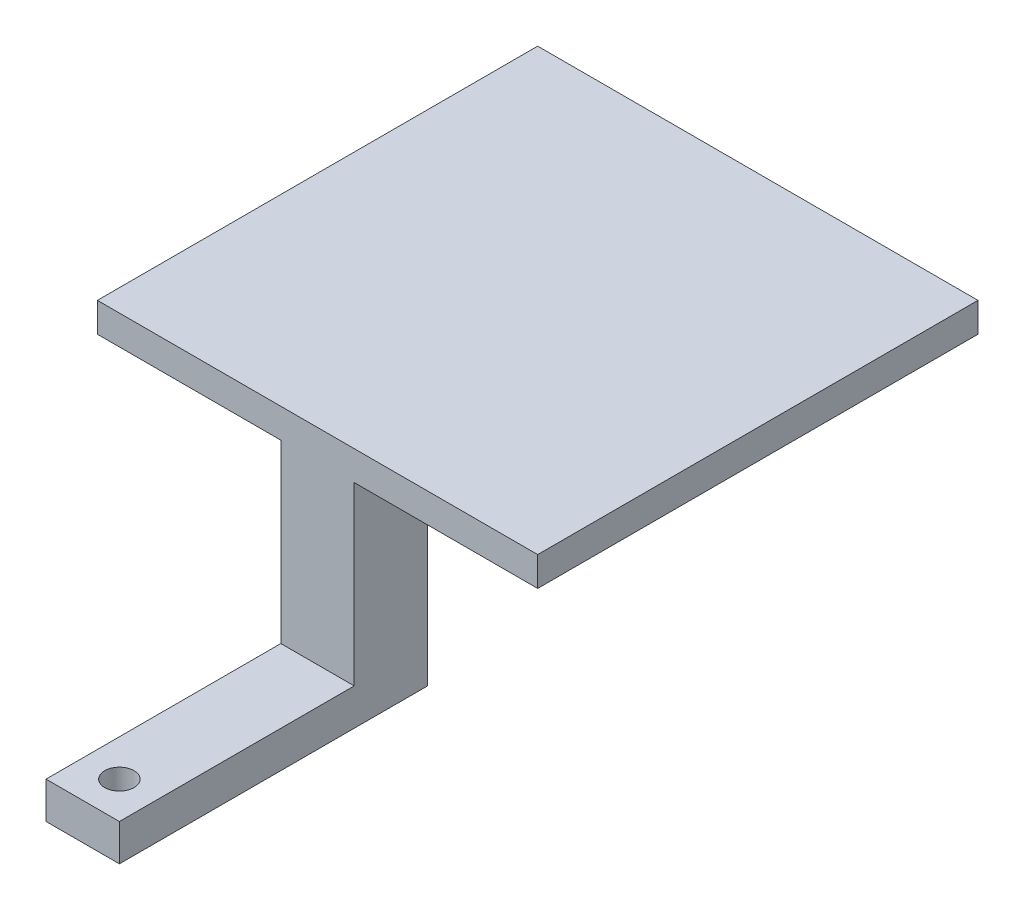
from build123d import *

# Parameters (mm, degrees)
SKETCH1_W           = 30
SKETCH1_H           = 30
BOSS_EXTRUDE1_DEPTH = 2
BOSS_EXTRUDE2_DEPTH = 14.5
SKETCH3_W           = 5
SKETCH3_H           = 2.5
BOSS_EXTRUDE3_DEPTH = 16
SKETCH4_R           = 1
CUT_EXTRUDE1_DEPTH  = 5


with BuildPart() as part:
    # Sketch1 → Boss-Extrude1 (new body)
    with BuildSketch(Plane(origin=(0, 0, 0), x_dir=(1, 0, 0), z_dir=(0, 1, 0))):
        Rectangle(SKETCH1_W, SKETCH1_H)
    extrude(amount=BOSS_EXTRUDE1_DEPTH)

    # Sketch2 → Boss-Extrude2 (add)
    with BuildSketch(Plane.XZ):
        Polygon((2.5, 15), (0, 15), (-2.5, 15), (-2.5, 10), (2.5, 10), align=None)
    extrude(amount=BOSS_EXTRUDE2_DEPTH)

    # Sketch3 → Boss-Extrude3 (add)
    with BuildSketch(Plane.XY.offset(15)):
        with Locations((0, -13.25)):
            Rectangle(SKETCH3_W, SKETCH3_H)
    extrude(amount=BOSS_EXTRUDE3_DEPTH)

    # Sketch4 → Cut-Extrude1 (cut)
    with BuildSketch(Plane(origin=(0, -14.5, 0), x_dir=(-1, 0, 0), z_dir=(0, -1, 0))):
        with Locations((0, -28.5)):
            Circle(SKETCH4_R)
    extrude(amount=-CUT_EXTRUDE1_DEPTH, mode=Mode.SUBTRACT)


solid = part.part
